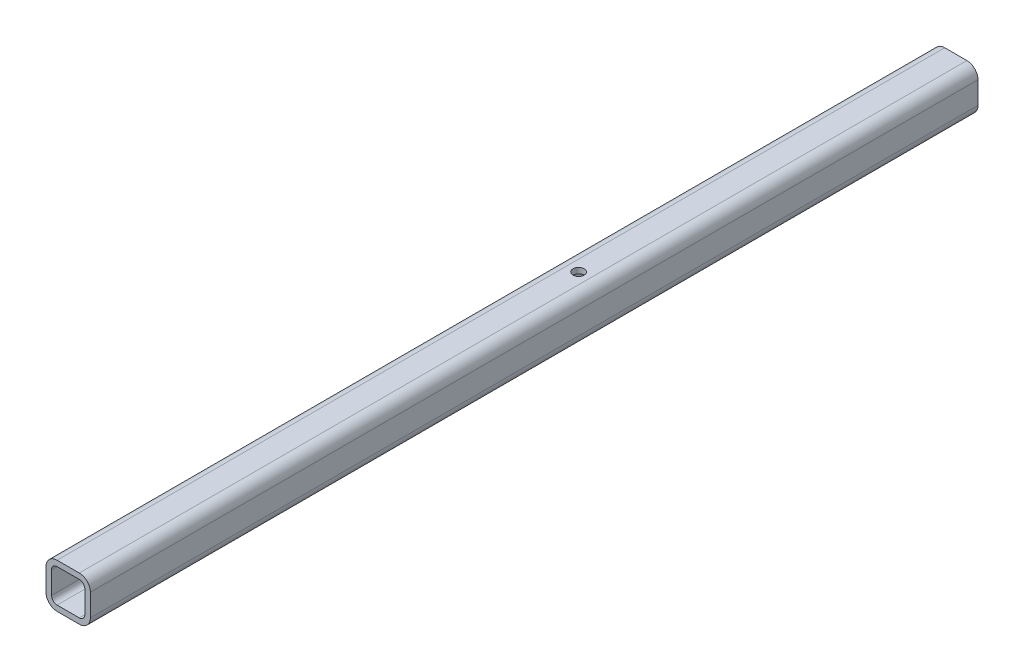
from build123d import *

# Parameters (mm, degrees)
BOSS_EXTRUDE1_DEPTH        = 508
F_1_2_0_5_DIAMETER_HOLE1_D = 12.7
CUT_EXTRUDE3_REACH         = 52.8


with BuildPart() as part:
    # Sketch1 → Boss-Extrude1 (new body, symmetric)
    with BuildSketch(Plane.XY):
        with BuildLine():
            Line((12.7, 0), (38.1, 0))
            ThreePointArc((38.1, 0), (47.080256121, 3.719743879), (50.8, 12.7))
            Line((50.8, 12.7), (50.8, 38.1))
            ThreePointArc((50.8, 38.1), (47.080256121, 47.080256121), (38.1, 50.8))
            Line((38.1, 50.8), (12.7, 50.8))
            ThreePointArc((12.7, 50.8), (3.719743879, 47.080256121), (0, 38.1))
            Line((0, 38.1), (0, 12.7))
            ThreePointArc((0, 12.7), (3.719743879, 3.719743879), (12.7, 0))
        make_face()
        with BuildLine():
            Line((12.7, 6.35), (38.1, 6.35))
            ThreePointArc((38.1, 6.35), (42.590128061, 8.209871939), (44.45, 12.7))
            Line((44.45, 12.7), (44.45, 38.1))
            ThreePointArc((44.45, 38.1), (42.590128061, 42.590128061), (38.1, 44.45))
            Line((38.1, 44.45), (12.7, 44.45))
            ThreePointArc((12.7, 44.45), (8.209871939, 42.590128061), (6.35, 38.1))
            Line((6.35, 38.1), (6.35, 12.7))
            ThreePointArc((6.35, 12.7), (8.209871939, 8.209871939), (12.7, 6.35))
        make_face(mode=Mode.SUBTRACT)
    extrude(amount=BOSS_EXTRUDE1_DEPTH, both=True)

    # 1/2 (0.5) Diameter Hole1 (through all)
    with Locations(Plane(origin=(0, 50.8, 0), x_dir=(-1, 0, 0), z_dir=(0, 1, 0))):
        with Locations((-25.4, -76.2)):
            Hole(F_1_2_0_5_DIAMETER_HOLE1_D / 2)

    # Sketch9 → Cut-Extrude3 (cut, up to next)
    with BuildSketch(Plane.XZ, mode=Mode.PRIVATE) as cut_extrude3_sk1:
        with BuildLine():
            Line((19.05, -488.95), (19.05, -469.9))
            ThreePointArc((19.05, -469.9), (25.4, -463.55), (31.75, -469.9))
            Line((31.75, -469.9), (31.75, -488.95))
            ThreePointArc((31.75, -488.95), (25.4, -495.3), (19.05, -488.95))
        make_face()
    cut_extrude3_tool1 = extrude(cut_extrude3_sk1.sketch, amount=-CUT_EXTRUDE3_REACH, mode=Mode.PRIVATE) & part.part
    add(cut_extrude3_tool1.solids().sort_by_distance((25.4, 0, -479.425))[0], mode=Mode.SUBTRACT)


solid = part.part
